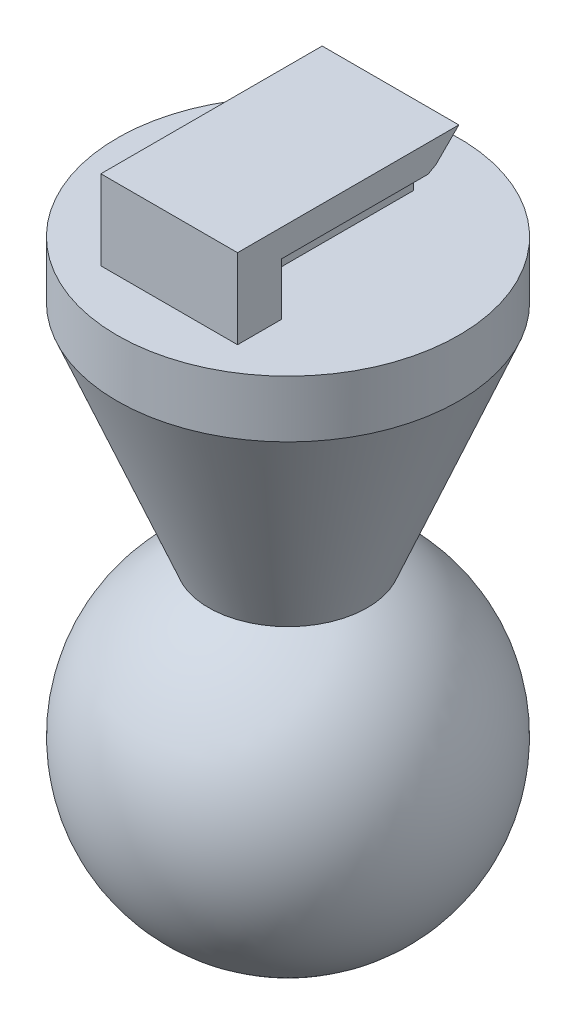
from build123d import *

# Parameters (mm, degrees)
SALIENTE_EXTRUIR1_DEPTH = 3
CROQUIS2_W              = 9
CROQUIS2_H              = 4
SALIENTE_EXTRUIR2_DEPTH = 1
CROQUIS3_R              = 7.5
SALIENTE_EXTRUIR3_DEPTH = 2
SALIENTE_EXTRUIR4_START = -3
CROQUIS7_W              = 0.714919667
CROQUIS7_H              = 4
SALIENTE_EXTRUIR4_DEPTH = 6
CROQUIS8_R              = 7.5
SALIENTE_EXTRUIR5_DEPTH = 0.5


with BuildPart() as part:
    # Croquis1 → Saliente-Extruir1 (new body, symmetric)
    with BuildSketch(Plane(origin=(0, 0, 0), x_dir=(0, 0, -1), z_dir=(1, 0, 0))):
        Polygon((0, 0), (0, 4), (9, 4), (8, 3), (1, 3), (1, 0), align=None)
    extrude(amount=SALIENTE_EXTRUIR1_DEPTH, both=True)

    # Croquis2 → Saliente-Extruir2 (add, symmetric)
    with BuildSketch(Plane(origin=(0, 0, 0), x_dir=(0, 0, -1), z_dir=(1, 0, 0))):
        with Locations((4.5, 2)):
            Rectangle(CROQUIS2_W, CROQUIS2_H)
    extrude(amount=SALIENTE_EXTRUIR2_DEPTH, both=True)

    # Croquis3 → Saliente-Extruir3 (add)
    with BuildSketch(Plane.XZ):
        with Locations((0, -4.5)):
            Circle(CROQUIS3_R)
    extrude(amount=SALIENTE_EXTRUIR3_DEPTH)

    # Croquis4 → Revolución1 (revolve)
    with BuildSketch(Plane(origin=(0, 0, 0), x_dir=(0, 0, -1), z_dir=(1, 0, 0))):
        Polygon((-3, -2), (1.475412378, -13), (4.5, -13), (4.5, -2), align=None)
    revolve(axis=Axis((0, -13, -4.5), (0, 1, 0)))

    # Croquis5 → Revolución2 (revolve)
    with BuildSketch(Plane(origin=(0, 0, 0), x_dir=(0, 0, -1), z_dir=(1, 0, 0))):
        with BuildLine():
            Line((4.5, -11), (4.5, -26))
            ThreePointArc((4.5, -26), (-3, -18.5), (4.5, -11))
        make_face()
    revolve(axis=Axis((0, -11, -4.5), (0, -1, 0)))

    # Croquis7 → Saliente-Extruir4 (add)
    with BuildSketch(Plane(origin=(0, 0, 0), x_dir=(0, 0, -1), z_dir=(1, 0, 0)).offset(SALIENTE_EXTRUIR4_START)):
        Polygon((1, 3), (1, 0), (1.204454973, 0), (1.204454973, 2.8), (7.653057768, 2.8), (8, 3), align=None)
        with Locations((-0.357459834, 2)):
            Rectangle(CROQUIS7_W, CROQUIS7_H)
    extrude(amount=SALIENTE_EXTRUIR4_DEPTH)

    # Croquis8 → Saliente-Extruir5 (add)
    with BuildSketch(Plane(origin=(0, 0, 0), x_dir=(1, 0, 0), z_dir=(0, 1, 0))):
        with Locations((0, 4.5)):
            Circle(CROQUIS8_R)
    extrude(amount=SALIENTE_EXTRUIR5_DEPTH)


solid = part.part
